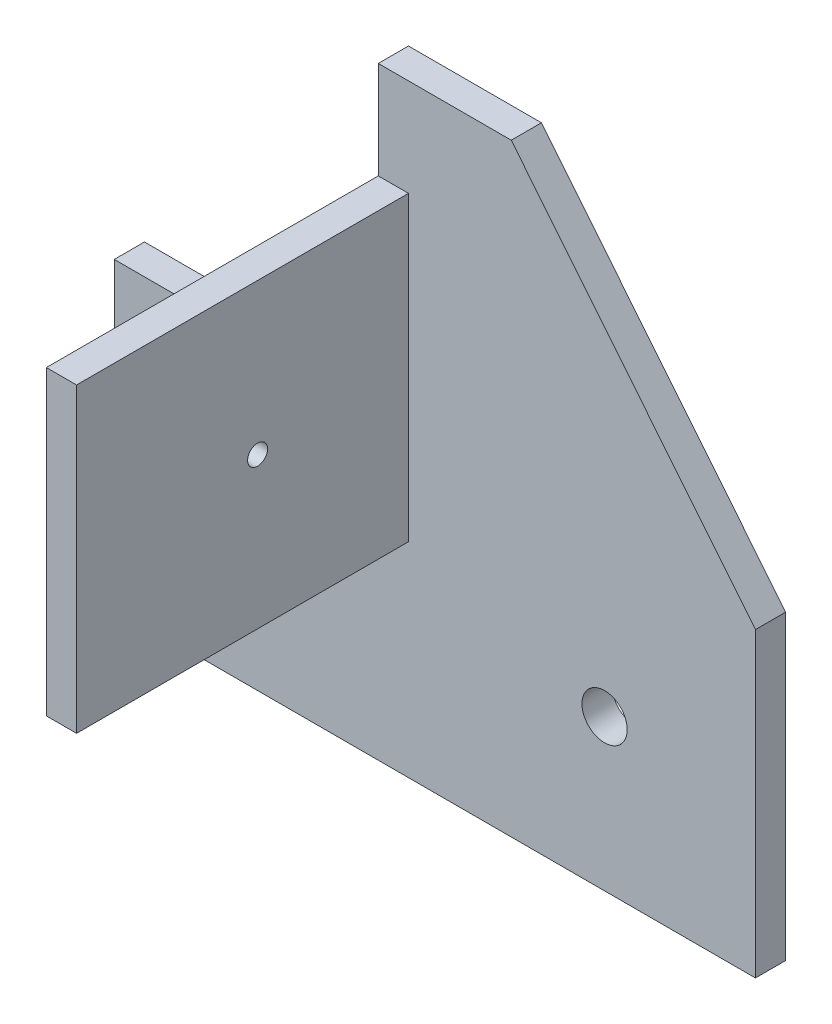
from build123d import *

# Parameters (mm, degrees)
SKIZZE1_R                       = 3
AUFSATZ_LINEAR_AUSTRAGEN1_DEPTH = 4
SKIZZE3_W                       = 48
SKIZZE3_H                       = 40
SKIZZE3_R                       = 1.324941068
AUFSATZ_LINEAR_AUSTRAGEN2_DEPTH = 4


with BuildPart() as part:
    # Skizze1 → Aufsatz-Linear austragen1 (new body)
    with BuildSketch(Plane.XY):
        Polygon((-78.13229572, 0), (-43.13229572, 0), (-43.13229572, 40), (-25.505836576, 40), (6.86770428, 0), (6.86770428, -40), (-78.13229572, -40), align=None)
        with Locations((-13.13229572, -20)):
            Circle(SKIZZE1_R, mode=Mode.SUBTRACT)
    extrude(amount=AUFSATZ_LINEAR_AUSTRAGEN1_DEPTH)

    # Skizze3 → Aufsatz-Linear austragen2 (add)
    with BuildSketch(Plane.ZY.offset(43.13229572)):
        with Locations((24, 7.085584289)):
            Rectangle(SKIZZE3_W, SKIZZE3_H)
        with Locations((24, 7.085584289)):
            Circle(SKIZZE3_R, mode=Mode.SUBTRACT)
    extrude(amount=-AUFSATZ_LINEAR_AUSTRAGEN2_DEPTH)


solid = part.part
